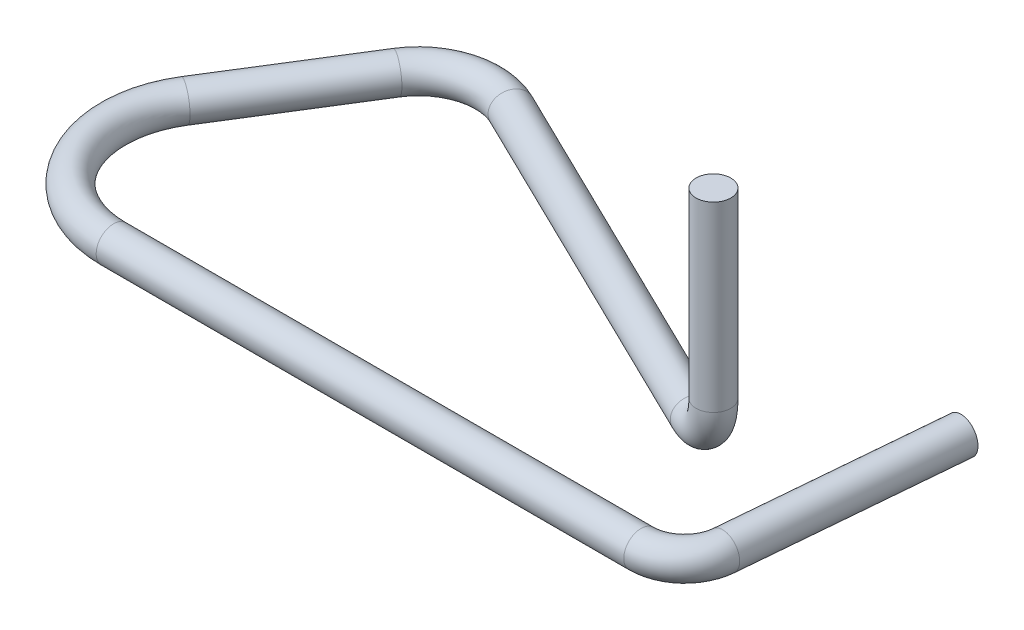
from build123d import *

# Parameters (mm, degrees)
SKETCH4_R = 0.508


with BuildPart() as part:
    # Sweep1: sweep along a curve in space
    with BuildLine() as sweep1_path:
        Line((17.526, 6.604, -4.102670361), (17.526, 1.27, -4.102670361))
        ThreePointArc((17.526, 1.27, -4.102670361), (17.191671635, 0.371974388, -4.2657332), (16.384531561, 0, -4.659401718))
        Line((16.384531561, 0, -4.659401718), (5.97077017, 0, -9.738532518))
        ThreePointArc((5.97077017, 0, -9.738532518), (4.519904893, 0, -9.865466782), (3.356766269, 0, -8.988978961))
        Line((3.356766269, 0, -8.988978961), (0.971149403, 0, -5.171193917))
        ThreePointArc((0.971149403, 0, -5.171193917), (0.890159133, 0, -2.078300277), (3.556, 0, -0.508))
        Line((3.556, 0, -0.508), (19.003402457, 0, -0.508))
        ThreePointArc((19.003402457, 0, -0.508), (19.861402021, 0, -0.841657782), (20.268569724, 0, -1.667312207))
        Line((20.268569724, 0, -1.667312207), (20.829933093, 0, -8.083724883))
    # Sketch4 → Sweep1 (sweep)
    with BuildSketch(Plane(origin=(0, 6.604, 0), x_dir=(1, 0, 0), z_dir=(0, 1, 0))):
        with Locations((17.526, 4.102670361)):
            Circle(SKETCH4_R)
    sweep(path=sweep1_path.line)


solid = part.part
